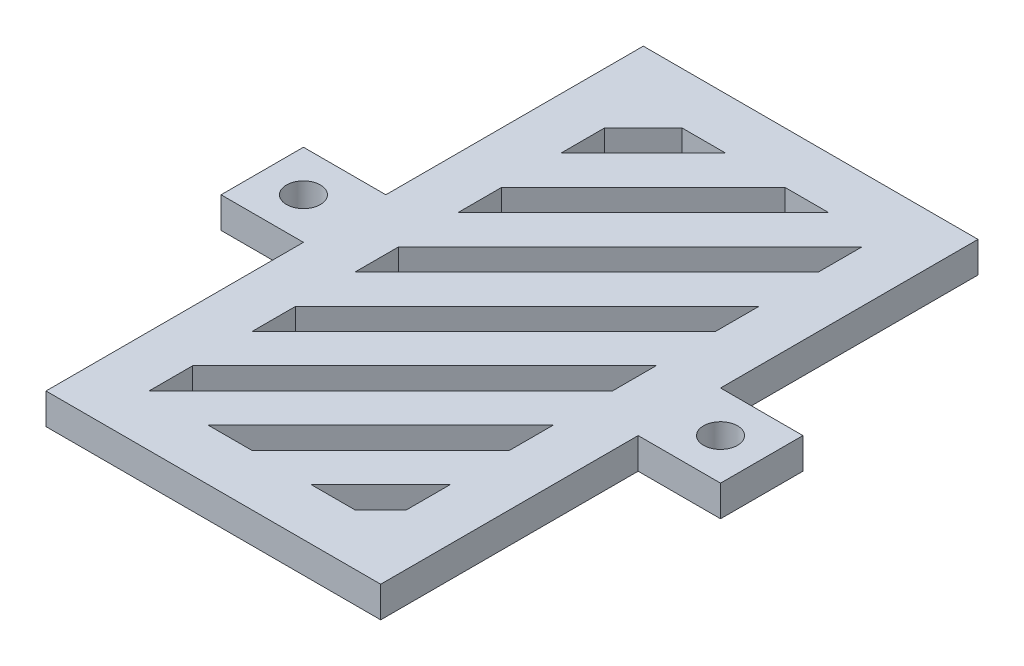
from build123d import *

# Parameters (mm, degrees)
SKETCH1_R           = 1.65
BOSS_EXTRUDE1_DEPTH = 3
CUT_EXTRUDE1_DEPTH  = 3


with BuildPart() as part:
    # Sketch1 → Boss-Extrude1 (new body)
    with BuildSketch(Plane(origin=(0, 0, 0), x_dir=(1, 0, 0), z_dir=(0, 1, 0))):
        Polygon((0, 25), (-8, 25), (-8, 33), (0, 33), (0, 58), (32.5, 58), (32.5, 33), (40.5, 33), (40.5, 25), (32.5, 25), (32.5, 0), (0, 0), align=None)
        with Locations((-4, 29)):
            Circle(SKETCH1_R, mode=Mode.SUBTRACT)
        with Locations((36.5, 29)):
            Circle(SKETCH1_R, mode=Mode.SUBTRACT)
    extrude(amount=BOSS_EXTRUDE1_DEPTH)

    # Sketch3 → Cut-Extrude1 (cut)
    with BuildSketch(Plane(origin=(0, 3, 0), x_dir=(1, 0, 0), z_dir=(0, 1, 0))):
        Polygon((10.757359313, 5), (15, 5), (27.5, 17.5), (27.5, 21.742640687), align=None)
        Polygon((5, 5), (5, 9.242640687), (27.5, 31.742640687), (27.5, 27.5), align=None)
        Polygon((8.757359313, 53), (13, 53), (5, 45), (5, 49.242640687), align=None)
        Polygon((5, 15), (27.5, 37.5), (27.5, 41.742640687), (5, 19.242640687), align=None)
        Polygon((5, 25), (27.5, 47.5), (27.5, 51.742640687), (5, 29.242640687), align=None)
        Polygon((5, 35), (23, 53), (18.757359313, 53), (5, 39.242640687), align=None)
        Polygon((25, 5), (27.5, 7.5), (27.5, 11.742640687), (20.757359313, 5), align=None)
    extrude(amount=-CUT_EXTRUDE1_DEPTH, mode=Mode.SUBTRACT)


solid = part.part
